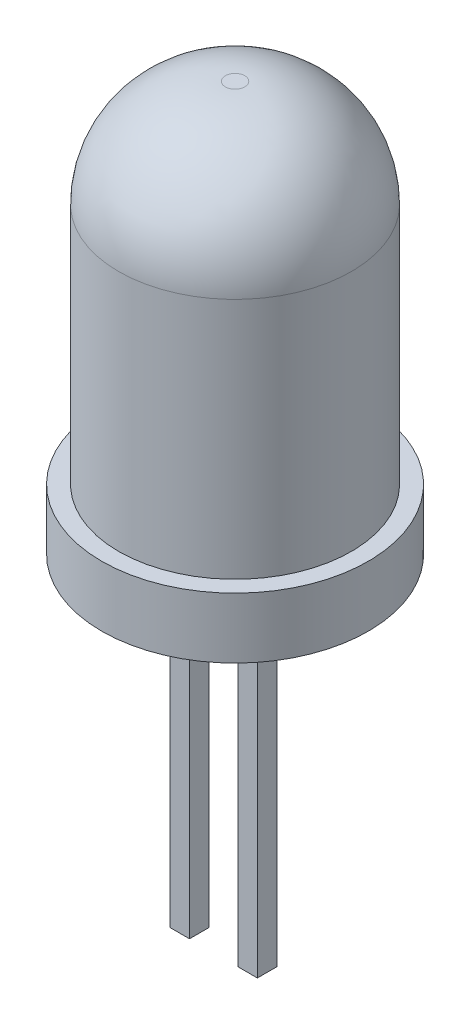
from build123d import *

# Parameters (mm, degrees)
SKETCH1_R           = 2.75
BOSS_EXTRUDE1_DEPTH = 1.25
SKETCH2_R           = 2.4
BOSS_EXTRUDE2_DEPTH = 7.2
FILLET1_R           = 2.2
SKETCH3_W           = 0.4
SKETCH3_H           = 0.4
BOSS_EXTRUDE3_DEPTH = 7.2


with BuildPart() as part:
    # Sketch1 → Boss-Extrude1 (new body)
    with BuildSketch(Plane(origin=(0, 0, 0), x_dir=(1, 0, 0), z_dir=(0, 1, 0))):
        Circle(SKETCH1_R)
    extrude(amount=BOSS_EXTRUDE1_DEPTH)

    # Sketch2 → Boss-Extrude2 (add)
    with BuildSketch(Plane(origin=(0, 1.25, 0), x_dir=(1, 0, 0), z_dir=(0, 1, 0))):
        Circle(SKETCH2_R)
    extrude(amount=BOSS_EXTRUDE2_DEPTH)

    # Fillet1
    fillet1_edges = [part.edges().sort_by_distance(p)[0] for p in [
        (-2.4, 8.45, 0),
    ]]
    fillet(fillet1_edges, radius=FILLET1_R)

    # Sketch3 → Boss-Extrude3 (add)
    with BuildSketch(Plane.XZ):
        with Locations((-1, -0.060309903)):
            Rectangle(SKETCH3_W, SKETCH3_H)
    boss_extrude3 = extrude(amount=BOSS_EXTRUDE3_DEPTH)

    # Mirror2: Boss-Extrude3 across plane
    add(boss_extrude3.mirror(Plane(origin=(-0.3, 0, 0), x_dir=(0, 0, 1), z_dir=(1, 0, 0))))


solid = part.part
